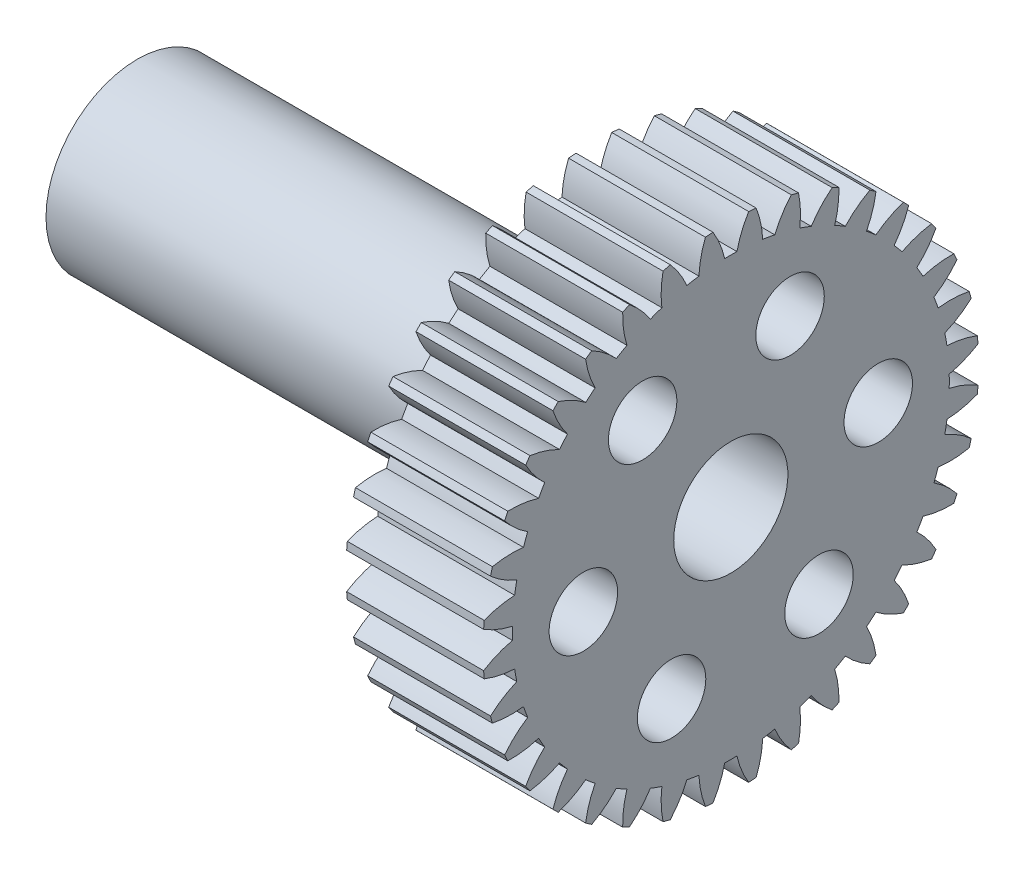
from build123d import *

# Parameters (mm, degrees)
BASPROSKE_W        = 19.05
BASPROSKE_H        = 34.471428571
TOOTHCUT_DEPTH     = 53.339863159
TEETHCUTS_COUNT    = 36
HUBNEAONESKE_R     = 12.7
HUBNEARONE_DEPTH   = 63.5000508
BORSKE_R           = 7.9375
BORE_DEPTH         = 82.5500508
SKETCH3_R          = 8.7376
CUT_EXTRUDE1_DEPTH = 15.875
SKETCH10_R         = 4.7625
CUT_EXTRUDE3_DEPTH = 19.05
CIRPATTERN3_COUNT  = 6


with BuildPart() as part:
    # BasProSke → Base-Revolve (revolve)
    with BuildSketch(Plane(origin=(0, 0, 0), x_dir=(1, 0, 0), z_dir=(0, 1, 0)), mode=Mode.PRIVATE) as base_revolve_sk:
        with Locations((9.525, 17.235714286)):
            Rectangle(BASPROSKE_W, BASPROSKE_H)
    revolve(base_revolve_sk.sketch.rotate(Axis((-10, 0, 0), (1, 0, 0)), 180), axis=Axis((-10, 0, 0), (1, 0, 0)))

    # TooCutSke → ToothCut (cut, through all)
    with BuildSketch(Plane(origin=(0, 0, 0), x_dir=(0, 0, -1), z_dir=(1, 0, 0))):
        with BuildLine():
            ThreePointArc((0.851731399, 30.37607698), (0, 30.388015714), (-0.851731399, 30.37607698))
            ThreePointArc((-0.851731399, 30.37607698), (-1.507519061, 32.460273588), (-2.501521053, 34.406010723))
            ThreePointArc((-2.501521053, 34.406010723), (0, 34.496828571), (2.501521053, 34.406010723))
            ThreePointArc((2.501521053, 34.406010723), (1.507519061, 32.460273588), (0.851731399, 30.37607698))
        make_face()
    toothcut = extrude(amount=TOOTHCUT_DEPTH, mode=Mode.SUBTRACT)

    # TeethCuts: ToothCut ×36 about axis
    teethcuts_axis = Axis((0, 0, 0), (1, 0, 0))
    for i in range(1, TEETHCUTS_COUNT):
        add(toothcut.rotate(teethcuts_axis, i * 360 / TEETHCUTS_COUNT), mode=Mode.SUBTRACT)

    # HubNeaOneSke → HubNearOne (add)
    with BuildSketch(Plane.ZY):
        with Locations(Location((0, 0, 0), (0, 0, 180))):
            Circle(HUBNEAONESKE_R)
    extrude(amount=HUBNEARONE_DEPTH)

    # BorSke → Bore (cut, symmetric)
    with BuildSketch(Plane(origin=(0, 0, 0), x_dir=(0, 0, -1), z_dir=(1, 0, 0))):
        with Locations(Location((0, 0, 0), (0, 0, 180))):
            Circle(BORSKE_R)
    extrude(amount=BORE_DEPTH, both=True, mode=Mode.SUBTRACT)

    # Sketch3 → Cut-Extrude1 (cut)
    with BuildSketch(Plane.ZY.offset(63.5000508)):
        Circle(SKETCH3_R)
    extrude(amount=-CUT_EXTRUDE1_DEPTH, mode=Mode.SUBTRACT)

    # Sketch10 → Cut-Extrude3 (cut)
    with BuildSketch(Plane(origin=(19.05, 0, 0), x_dir=(0, 0, -1), z_dir=(1, 0, 0))):
        with Locations((-12.265370213, 16.597201565)):
            Circle(SKETCH10_R)
    cut_extrude3 = extrude(amount=-CUT_EXTRUDE3_DEPTH, mode=Mode.SUBTRACT)

    # CirPattern3: Cut-Extrude3 ×6 about axis
    cirpattern3_axis = Axis((0, 0, 0), (1, 0, 0))
    for i in range(1, CIRPATTERN3_COUNT):
        add(cut_extrude3.rotate(cirpattern3_axis, i * 360 / CIRPATTERN3_COUNT), mode=Mode.SUBTRACT)


solid = part.part
